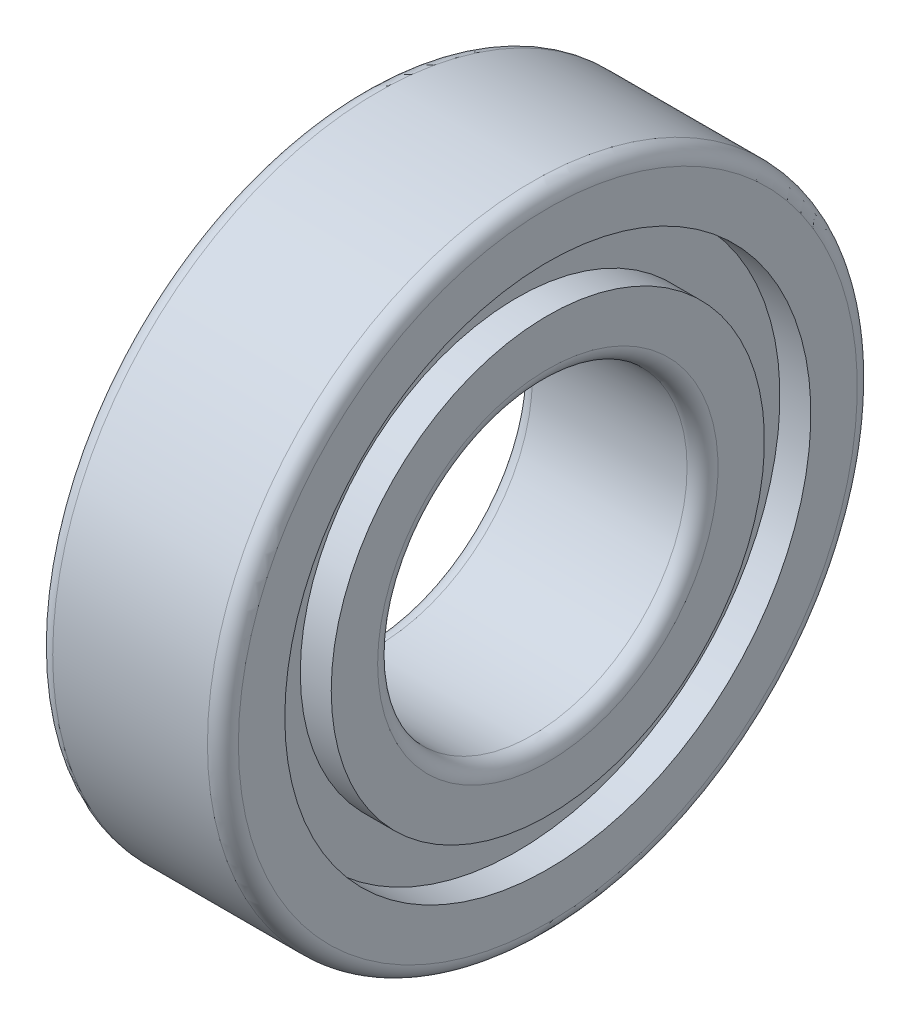
from build123d import *


with BuildPart() as part:
    # Эскиз1 → Повернуть1 (revolve)
    with BuildSketch(Plane.XY):
        with BuildLine():
            Line((5, 10), (-5, 10))
            ThreePointArc((-5, 10), (-5.707106781, 10.292893219), (-6, 11))
            Line((-6, 11), (-6, 14))
            Line((-6, 14), (-4, 14))
            Line((-4, 14), (-4, 17))
            Line((-4, 17), (-6, 17))
            Line((-6, 17), (-6, 20))
            ThreePointArc((-6, 20), (-5.707106781, 20.707106781), (-5, 21))
            Line((-5, 21), (5, 21))
            ThreePointArc((5, 21), (5.707106781, 20.707106781), (6, 20))
            Line((6, 20), (6, 17))
            Line((6, 17), (4, 17))
            Line((4, 17), (4, 14))
            Line((4, 14), (6, 14))
            Line((6, 14), (6, 11))
            ThreePointArc((6, 11), (5.707106781, 10.292893219), (5, 10))
        make_face()
    revolve(axis=Axis((-1000, 0, 0), (1, 0, 0)))


solid = part.part
